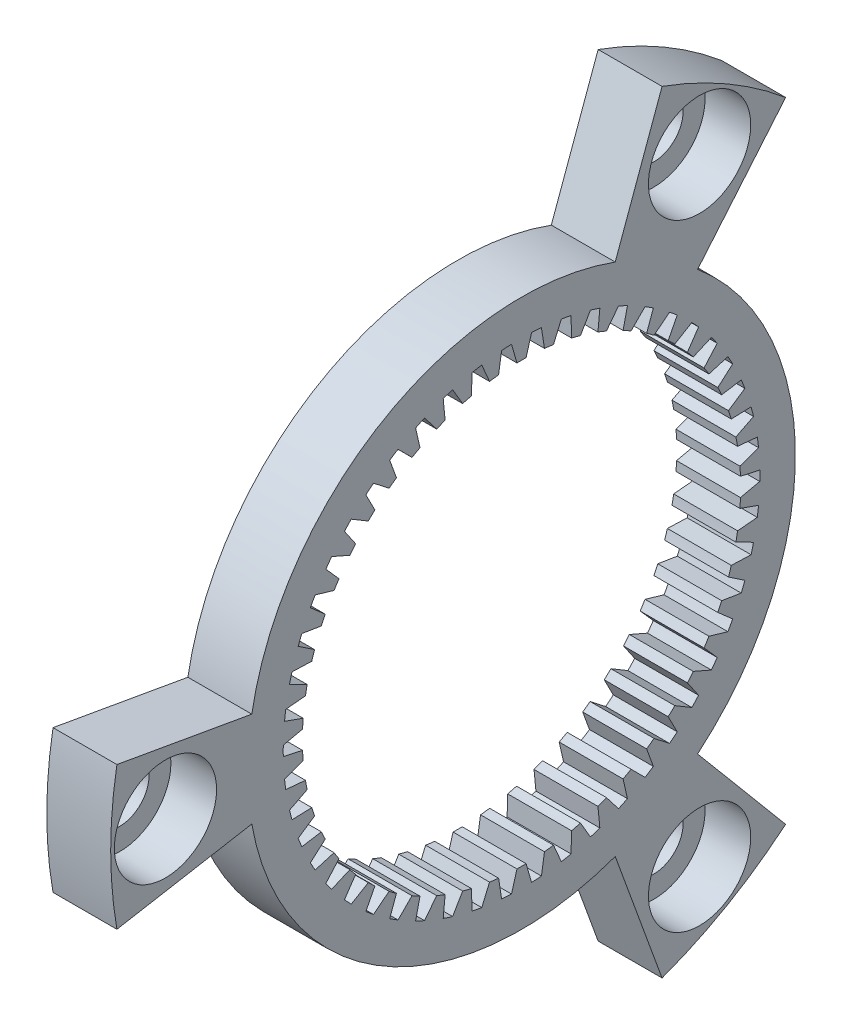
from build123d import *

# Parameters (mm, degrees)
SKETCH1_W                                        = 3.5
SKETCH1_H                                        = 22.5
CUT_EXTRUDE1_DEPTH                               = 4.5
CUT_EXTRUDE2_DEPTH                               = 4.5
CUT_EXTRUDE3_DEPTH                               = 4.5
CUT_EXTRUDE4_DEPTH                               = 4.5
CBORE_FOR_M3_HEX_HEAD_MACHINE_SCREW1_D           = 3.2
CBORE_FOR_M3_HEX_HEAD_MACHINE_SCREW1_CBORE_D     = 5.6
CBORE_FOR_M3_HEX_HEAD_MACHINE_SCREW1_CBORE_DEPTH = 2.5


with BuildPart() as part:
    # Sketch1 → Revolve1 (revolve)
    with BuildSketch(Plane.XY):
        with Locations((0.25, 11.25)):
            Rectangle(SKETCH1_W, SKETCH1_H)
    revolve(axis=Axis((-1.5, 0, 0), (1, 0, 0)))

    # Sketch2 → Cut-Extrude1 (cut, through all)
    with BuildSketch(Plane.ZY.offset(1.5)):
        with BuildLine():
            Line((22.158174437, -3.907084003), (14.77211629, -2.604722668))
            ThreePointArc((14.77211629, -2.604722668), (7.499999995, -12.990381056), (-5.130302151, -14.095389311))
            Line((-5.130302151, -14.095389311), (-7.695453225, -21.143083968))
            ThreePointArc((-7.695453225, -21.143083968), (11.249999994, -19.485571584), (22.158174437, -3.907084003))
        make_face()
    extrude(amount=-CUT_EXTRUDE1_DEPTH, mode=Mode.SUBTRACT)

    # Sketch3 → Cut-Extrude2 (cut, through all)
    with BuildSketch(Plane.ZY.offset(1.5)):
        with BuildLine():
            Line((-14.462721218, -17.23599997), (-9.641814144, -11.490666648))
            ThreePointArc((-9.641814144, -11.490666648), (-14.999999996, -2e-09), (-9.641814142, 11.490666643))
            Line((-9.641814142, 11.490666643), (-14.462721215, 17.235999966))
            ThreePointArc((-14.462721215, 17.235999966), (-22.499999996, -1e-09), (-14.462721218, -17.23599997))
        make_face()
    extrude(amount=-CUT_EXTRUDE2_DEPTH, mode=Mode.SUBTRACT)

    # Sketch4 → Cut-Extrude3 (cut, through all)
    with BuildSketch(Plane.ZY.offset(1.5)):
        with BuildLine():
            Line((-7.695453229, 21.143083966), (-5.130302153, 14.095389311))
            ThreePointArc((-5.130302153, 14.095389311), (7.500000001, 12.990381056), (14.772116296, 2.60472266))
            Line((14.772116296, 2.60472266), (22.158174444, 3.90708399))
            ThreePointArc((22.158174444, 3.90708399), (11.250000001, 19.485571584), (-7.695453229, 21.143083966))
        make_face()
    extrude(amount=-CUT_EXTRUDE3_DEPTH, mode=Mode.SUBTRACT)

    # Sketch5 → Cut-Extrude4 (cut, through all)
    with BuildSketch(Plane.ZY.offset(1.5)):
        with BuildLine():
            Line((11.958023801, 1.002829383), (12.978235019, 1.366717155))
            ThreePointArc((12.978235019, 1.366717155), (12.947096852, 1.635598699), (12.910388636, 1.903776582))
            Line((12.910388636, 1.903776582), (11.83173402, 2.002515937))
            ThreePointArc((11.83173402, 2.002515937), (11.787447009, 2.248575775), (11.738043363, 2.493659563))
            Line((11.738043363, 2.493659563), (12.704602679, 2.982544343))
            ThreePointArc((12.704602679, 2.982544343), (12.640010253, 3.245403028), (12.569979891, 3.506865488))
            Line((12.569979891, 3.506865488), (11.487455466, 3.469634984))
            ThreePointArc((11.487455466, 3.469634984), (11.412678196, 3.708203932), (11.332946969, 3.945163242))
            Line((11.332946969, 3.945163242), (12.230611166, 4.551335025))
            ThreePointArc((12.230611166, 4.551335025), (12.133583141, 4.804025412), (12.031335054, 5.05464903))
            Line((12.031335054, 5.05464903), (10.962012876, 4.882035815))
            ThreePointArc((10.962012876, 4.882035815), (10.85792463, 5.109351498), (10.749123231, 5.33444934))
            Line((10.749123231, 5.33444934), (11.563735608, 6.048348435))
            ThreePointArc((11.563735608, 6.048348435), (11.435802174, 6.286885447), (11.302948875, 6.522717741))
            Line((11.302948875, 6.522717741), (10.263692795, 6.217444025))
            ThreePointArc((10.263692795, 6.217444025), (10.131935106, 6.429921539), (9.995779399, 6.639607986))
            Line((9.995779399, 6.639607986), (10.714493032, 7.449975777))
            ThreePointArc((10.714493032, 7.449975777), (10.557671777, 7.670597542), (10.396308442, 7.887919293))
            Line((10.396308442, 7.887919293), (9.403508148, 7.454799428))
            ThreePointArc((9.403508148, 7.454799428), (9.246158914, 7.649087876), (9.084796155, 7.840056047))
            Line((9.084796155, 7.840056047), (9.6962765, 8.73411255))
            ThreePointArc((9.6962765, 8.73411255), (9.513040588, 8.933339732), (9.325712014, 9.128723647))
            Line((9.325712014, 9.128723647), (8.39502456, 8.574588191))
            ThreePointArc((8.39502456, 8.574588191), (8.21456527, 8.74762353), (8.030540244, 8.916861745))
            Line((8.030540244, 8.916861745), (8.525143895, 9.880507151))
            ThreePointArc((8.525143895, 9.880507151), (8.318383067, 10.055197817), (8.108043537, 10.225562576))
            Line((8.108043537, 10.225562576), (7.254146419, 9.559150576))
            ThreePointArc((7.254146419, 9.559150576), (7.053423027, 9.708203933), (6.849637921, 9.853043203))
            Line((6.849637921, 9.853043203), (7.219564679, 10.871080252))
            ThreePointArc((7.219564679, 10.871080252), (6.992539674, 11.018479428), (6.762506366, 11.161138278))
            Line((6.762506366, 11.161138278), (5.998866056, 10.392959446))
            ThreePointArc((5.998866056, 10.392959446), (5.781044088, 10.515680161), (5.560712715, 10.633836283))
            Line((5.560712715, 10.633836283), (5.800128615, 11.690209923))
            ThreePointArc((5.800128615, 11.690209923), (5.556419755, 11.807993035), (5.310320434, 11.920696158))
            Line((5.310320434, 11.920696158), (4.648979992, 11.062865137))
            ThreePointArc((4.648979992, 11.062865137), (4.417494632, 11.157317831), (4.184091749, 11.246927413))
            Line((4.184091749, 11.246927413), (4.289221057, 12.324978001))
            ThreePointArc((4.289221057, 12.324978001), (4.032671777, 12.411287537), (3.774387577, 12.492257539))
            Line((3.774387577, 12.492257539), (3.225776736, 11.558302836))
            ThreePointArc((3.225776736, 11.558302836), (2.984278646, 11.622997933), (2.741485156, 11.682647779))
            Line((2.741485156, 11.682647779), (2.710669922, 12.765373812))
            ThreePointArc((2.710669922, 12.765373812), (2.445326155, 12.818848622), (2.17893037, 12.866808557))
            Line((2.17893037, 12.866808557), (1.751701054, 11.871459195))
            ThreePointArc((1.751701054, 11.871459195), (1.503998804, 11.905376416), (1.255643705, 11.934125811))
            Line((1.255643705, 11.934125811), (1.089369902, 13.004452054))
            ThreePointArc((1.089369902, 13.004452054), (0.81941628, 13.024248806), (0.549110132, 13.038442317))
            Line((0.549110132, 13.038442317), (0.25, 11.997395551))
            ThreePointArc((0.25, 11.997395551), (1e-09, 12), (-0.249999997, 11.997395551))
            Line((-0.249999997, 11.997395551), (-0.549110132, 13.038442317))
            ThreePointArc((-0.549110132, 13.038442317), (-0.819416279, 13.024248806), (-1.0893699, 13.004452054))
            Line((-1.0893699, 13.004452054), (-1.255643703, 11.934125812))
            ThreePointArc((-1.255643703, 11.934125812), (-1.503998803, 11.905376416), (-1.751701056, 11.871459195))
            Line((-1.751701056, 11.871459195), (-2.17893037, 12.866808557))
            ThreePointArc((-2.17893037, 12.866808557), (-2.445326153, 12.818848622), (-2.710669918, 12.765373813))
            Line((-2.710669918, 12.765373813), (-2.741485155, 11.68264778))
            ThreePointArc((-2.741485155, 11.68264778), (-2.984278646, 11.622997933), (-3.225776737, 11.558302836))
            Line((-3.225776737, 11.558302836), (-3.774387576, 12.492257539))
            ThreePointArc((-3.774387576, 12.492257539), (-4.032671778, 12.411287537), (-4.289221059, 12.324978))
            Line((-4.289221059, 12.324978), (-4.184091749, 11.246927413))
            ThreePointArc((-4.184091749, 11.246927413), (-4.417494632, 11.157317831), (-4.648979992, 11.062865137))
            Line((-4.648979992, 11.062865137), (-5.310320434, 11.920696158))
            ThreePointArc((-5.310320434, 11.920696158), (-5.556419755, 11.807993035), (-5.800128615, 11.690209923))
            Line((-5.800128615, 11.690209923), (-5.560712716, 10.633836283))
            ThreePointArc((-5.560712716, 10.633836283), (-5.781044089, 10.515680161), (-5.998866056, 10.392959446))
            Line((-5.998866056, 10.392959446), (-6.762506367, 11.161138277))
            ThreePointArc((-6.762506367, 11.161138277), (-6.992539674, 11.018479428), (-7.219564678, 10.871080253))
            Line((-7.219564678, 10.871080253), (-6.849637922, 9.853043202))
            ThreePointArc((-6.849637922, 9.853043202), (-7.053423027, 9.708203933), (-7.254146418, 9.559150576))
            Line((-7.254146418, 9.559150576), (-8.108043535, 10.225562578))
            ThreePointArc((-8.108043535, 10.225562578), (-8.318383066, 10.055197818), (-8.525143896, 9.880507151))
            Line((-8.525143896, 9.880507151), (-8.030540246, 8.916861744))
            ThreePointArc((-8.030540246, 8.916861744), (-8.21456527, 8.74762353), (-8.395024558, 8.574588192))
            Line((-8.395024558, 8.574588192), (-9.325712013, 9.128723648))
            ThreePointArc((-9.325712013, 9.128723648), (-9.513040588, 8.933339732), (-9.696276499, 8.73411255))
            Line((-9.696276499, 8.73411255), (-9.084796153, 7.840056049))
            ThreePointArc((-9.084796153, 7.840056049), (-9.246158912, 7.649087878), (-9.403508146, 7.45479943))
            Line((-9.403508146, 7.45479943), (-10.396308442, 7.887919294))
            ThreePointArc((-10.396308442, 7.887919294), (-10.557671776, 7.670597543), (-10.714493031, 7.449975778))
            Line((-10.714493031, 7.449975778), (-9.995779398, 6.639607987))
            ThreePointArc((-9.995779398, 6.639607987), (-10.131935107, 6.429921539), (-10.263692796, 6.217444023))
            Line((-10.263692796, 6.217444023), (-11.302948876, 6.52271774))
            ThreePointArc((-11.302948876, 6.52271774), (-11.435802174, 6.286885448), (-11.563735606, 6.048348438))
            Line((-11.563735606, 6.048348438), (-10.749123231, 5.334449341))
            ThreePointArc((-10.749123231, 5.334449341), (-10.85792463, 5.109351498), (-10.962012877, 4.882035814))
            Line((-10.962012877, 4.882035814), (-12.031335054, 5.054649031))
            ThreePointArc((-12.031335054, 5.054649031), (-12.133583141, 4.804025412), (-12.230611166, 4.551335023))
            Line((-12.230611166, 4.551335023), (-11.332946969, 3.945163242))
            ThreePointArc((-11.332946969, 3.945163242), (-11.412678196, 3.708203932), (-11.487455466, 3.469634984))
            Line((-11.487455466, 3.469634984), (-12.569979891, 3.506865487))
            ThreePointArc((-12.569979891, 3.506865487), (-12.640010253, 3.245403027), (-12.704602679, 2.982544343))
            Line((-12.704602679, 2.982544343), (-11.738043363, 2.493659563))
            ThreePointArc((-11.738043363, 2.493659563), (-11.787447009, 2.248575775), (-11.83173402, 2.002515937))
            Line((-11.83173402, 2.002515937), (-12.910388636, 1.90377658))
            ThreePointArc((-12.910388636, 1.90377658), (-12.947096852, 1.635598698), (-12.978235019, 1.366717156))
            Line((-12.978235019, 1.366717156), (-11.958023801, 1.002829382))
            ThreePointArc((-11.958023801, 1.002829382), (-11.976320741, 0.753486235), (-11.989419061, 0.503816019))
            Line((-11.989419061, 0.503816019), (-13.04719284, 0.270663979))
            ThreePointArc((-13.04719284, 0.270663979), (-13.05, -1e-09), (-13.04719284, -0.270663981))
            Line((-13.04719284, -0.270663981), (-11.989419061, -0.503816018))
            ThreePointArc((-11.989419061, -0.503816018), (-11.976320741, -0.753486235), (-11.958023801, -1.002829382))
            Line((-11.958023801, -1.002829382), (-12.978235019, -1.366717157))
            ThreePointArc((-12.978235019, -1.366717157), (-12.947096852, -1.635598699), (-12.910388636, -1.90377658))
            Line((-12.910388636, -1.90377658), (-11.83173402, -2.002515936))
            ThreePointArc((-11.83173402, -2.002515936), (-11.787447009, -2.248575775), (-11.738043363, -2.493659563))
            Line((-11.738043363, -2.493659563), (-12.704602679, -2.982544343))
            ThreePointArc((-12.704602679, -2.982544343), (-12.640010253, -3.245403027), (-12.569979891, -3.506865487))
            Line((-12.569979891, -3.506865487), (-11.487455466, -3.469634983))
            ThreePointArc((-11.487455466, -3.469634983), (-11.412678196, -3.708203931), (-11.332946969, -3.945163242))
            Line((-11.332946969, -3.945163242), (-12.230611166, -4.551335024))
            ThreePointArc((-12.230611166, -4.551335024), (-12.133583141, -4.804025412), (-12.031335054, -5.054649031))
            Line((-12.031335054, -5.054649031), (-10.962012877, -4.882035813))
            ThreePointArc((-10.962012877, -4.882035813), (-10.85792463, -5.109351497), (-10.749123231, -5.334449341))
            Line((-10.749123231, -5.334449341), (-11.563735609, -6.048348433))
            ThreePointArc((-11.563735609, -6.048348433), (-11.435802175, -6.286885446), (-11.302948876, -6.52271774))
            Line((-11.302948876, -6.52271774), (-10.263692794, -6.217444027))
            ThreePointArc((-10.263692794, -6.217444027), (-10.131935105, -6.429921541), (-9.995779398, -6.639607987))
            Line((-9.995779398, -6.639607987), (-10.714493034, -7.449975773))
            ThreePointArc((-10.714493034, -7.449975773), (-10.557671778, -7.670597541), (-10.396308442, -7.887919294))
            Line((-10.396308442, -7.887919294), (-9.403508147, -7.454799429))
            ThreePointArc((-9.403508147, -7.454799429), (-9.246158913, -7.649087878), (-9.084796153, -7.840056049))
            Line((-9.084796153, -7.840056049), (-9.696276504, -8.734112546))
            ThreePointArc((-9.696276504, -8.734112546), (-9.51304059, -8.93333973), (-9.325712013, -9.128723648))
            Line((-9.325712013, -9.128723648), (-8.395024559, -8.574588191))
            ThreePointArc((-8.395024559, -8.574588191), (-8.214565271, -8.747623529), (-8.030540246, -8.916861744))
            Line((-8.030540246, -8.916861744), (-8.525143893, -9.880507153))
            ThreePointArc((-8.525143893, -9.880507153), (-8.318383065, -10.055197819), (-8.108043535, -10.225562578))
            Line((-8.108043535, -10.225562578), (-7.254146419, -9.559150576))
            ThreePointArc((-7.254146419, -9.559150576), (-7.053423027, -9.708203933), (-6.849637922, -9.853043202))
            Line((-6.849637922, -9.853043202), (-7.219564677, -10.871080253))
            ThreePointArc((-7.219564677, -10.871080253), (-6.992539674, -11.018479428), (-6.762506367, -11.161138277))
            Line((-6.762506367, -11.161138277), (-5.998866057, -10.392959445))
            ThreePointArc((-5.998866057, -10.392959445), (-5.78104409, -10.51568016), (-5.560712716, -10.633836283))
            Line((-5.560712716, -10.633836283), (-5.800128615, -11.690209923))
            ThreePointArc((-5.800128615, -11.690209923), (-5.556419755, -11.807993035), (-5.310320434, -11.920696158))
            Line((-5.310320434, -11.920696158), (-4.648979993, -11.062865136))
            ThreePointArc((-4.648979993, -11.062865136), (-4.417494633, -11.15731783), (-4.184091749, -11.246927413))
            Line((-4.184091749, -11.246927413), (-4.289221058, -12.324978))
            ThreePointArc((-4.289221058, -12.324978), (-4.032671777, -12.411287537), (-3.774387576, -12.492257539))
            Line((-3.774387576, -12.492257539), (-3.225776739, -11.558302835))
            ThreePointArc((-3.225776739, -11.558302835), (-2.984278647, -11.622997933), (-2.741485155, -11.68264778))
            Line((-2.741485155, -11.68264778), (-2.710669925, -12.765373812))
            ThreePointArc((-2.710669925, -12.765373812), (-2.445326157, -12.818848622), (-2.17893037, -12.866808557))
            Line((-2.17893037, -12.866808557), (-1.751701051, -11.871459195))
            ThreePointArc((-1.751701051, -11.871459195), (-1.503998801, -11.905376416), (-1.255643703, -11.934125812))
            Line((-1.255643703, -11.934125812), (-1.089369906, -13.004452053))
            ThreePointArc((-1.089369906, -13.004452053), (-0.819416282, -13.024248806), (-0.549110132, -13.038442317))
            Line((-0.549110132, -13.038442317), (-0.249999998, -11.997395551))
            ThreePointArc((-0.249999998, -11.997395551), (1e-09, -12), (0.25, -11.997395551))
            Line((0.25, -11.997395551), (0.549110126, -13.038442317))
            ThreePointArc((0.549110126, -13.038442317), (0.819416277, -13.024248806), (1.089369902, -13.004452054))
            Line((1.089369902, -13.004452054), (1.255643704, -11.934125812))
            ThreePointArc((1.255643704, -11.934125812), (1.503998803, -11.905376416), (1.751701054, -11.871459195))
            Line((1.751701054, -11.871459195), (2.178930373, -12.866808556))
            ThreePointArc((2.178930373, -12.866808556), (2.445326157, -12.818848622), (2.710669922, -12.765373812))
            Line((2.710669922, -12.765373812), (2.741485155, -11.68264778))
            ThreePointArc((2.741485155, -11.68264778), (2.984278646, -11.622997934), (3.225776736, -11.558302836))
            Line((3.225776736, -11.558302836), (3.774387577, -12.492257539))
            ThreePointArc((3.774387577, -12.492257539), (4.032671777, -12.411287537), (4.289221057, -12.324978001))
            Line((4.289221057, -12.324978001), (4.184091748, -11.246927413))
            ThreePointArc((4.184091748, -11.246927413), (4.417494632, -11.157317831), (4.648979992, -11.062865137))
            Line((4.648979992, -11.062865137), (5.310320434, -11.920696158))
            ThreePointArc((5.310320434, -11.920696158), (5.556419755, -11.807993034), (5.800128615, -11.690209923))
            Line((5.800128615, -11.690209923), (5.560712715, -10.633836283))
            ThreePointArc((5.560712715, -10.633836283), (5.781044088, -10.515680161), (5.998866056, -10.392959446))
            Line((5.998866056, -10.392959446), (6.762506366, -11.161138277))
            ThreePointArc((6.762506366, -11.161138277), (6.992539674, -11.018479428), (7.219564679, -10.871080252))
            Line((7.219564679, -10.871080252), (6.84963792, -9.853043203))
            ThreePointArc((6.84963792, -9.853043203), (7.053423026, -9.708203933), (7.254146419, -9.559150576))
            Line((7.254146419, -9.559150576), (8.108043533, -10.225562579))
            ThreePointArc((8.108043533, -10.225562579), (8.318383065, -10.055197819), (8.525143895, -9.880507151))
            Line((8.525143895, -9.880507151), (8.030540248, -8.916861742))
            ThreePointArc((8.030540248, -8.916861742), (8.214565272, -8.747623528), (8.39502456, -8.574588191))
            Line((8.39502456, -8.574588191), (9.32571201, -9.128723651))
            ThreePointArc((9.32571201, -9.128723651), (9.513040587, -8.933339734), (9.6962765, -8.73411255))
            Line((9.6962765, -8.73411255), (9.084796154, -7.840056048))
            ThreePointArc((9.084796154, -7.840056048), (9.246158914, -7.649087876), (9.403508148, -7.454799428))
            Line((9.403508148, -7.454799428), (10.396308438, -7.887919298))
            ThreePointArc((10.396308438, -7.887919298), (10.557671775, -7.670597545), (10.714493032, -7.449975777))
            Line((10.714493032, -7.449975777), (9.995779399, -6.639607986))
            ThreePointArc((9.995779399, -6.639607986), (10.131935106, -6.429921539), (10.263692795, -6.217444025))
            Line((10.263692795, -6.217444025), (11.302948877, -6.522717737))
            ThreePointArc((11.302948877, -6.522717737), (11.435802175, -6.286885446), (11.563735608, -6.048348435))
            Line((11.563735608, -6.048348435), (10.749123231, -5.334449341))
            ThreePointArc((10.749123231, -5.334449341), (10.85792463, -5.109351498), (10.962012876, -4.882035815))
            Line((10.962012876, -4.882035815), (12.031335054, -5.05464903))
            ThreePointArc((12.031335054, -5.05464903), (12.133583141, -4.804025412), (12.230611166, -4.551335025))
            Line((12.230611166, -4.551335025), (11.332946968, -3.945163243))
            ThreePointArc((11.332946968, -3.945163243), (11.412678195, -3.708203933), (11.487455466, -3.469634984))
            Line((11.487455466, -3.469634984), (12.569979891, -3.506865487))
            ThreePointArc((12.569979891, -3.506865487), (12.640010253, -3.245403027), (12.704602679, -2.982544343))
            Line((12.704602679, -2.982544343), (11.738043362, -2.493659564))
            ThreePointArc((11.738043362, -2.493659564), (11.787447009, -2.248575776), (11.83173402, -2.002515937))
            Line((11.83173402, -2.002515937), (12.910388636, -1.903776581))
            ThreePointArc((12.910388636, -1.903776581), (12.947096852, -1.635598699), (12.978235019, -1.366717155))
            Line((12.978235019, -1.366717155), (11.958023801, -1.002829385))
            ThreePointArc((11.958023801, -1.002829385), (11.976320741, -0.753486236), (11.989419061, -0.503816018))
            Line((11.989419061, -0.503816018), (13.04719284, -0.27066398))
            ThreePointArc((13.04719284, -0.27066398), (13.05, -1e-09), (13.04719284, 0.270663979))
            Line((13.04719284, 0.270663979), (11.989419061, 0.503816018))
            ThreePointArc((11.989419061, 0.503816018), (11.976320741, 0.753486235), (11.958023801, 1.002829383))
        make_face()
    extrude(amount=-CUT_EXTRUDE4_DEPTH, mode=Mode.SUBTRACT)

    # CBORE for M3 Hex Head Machine Screw1 (through all)
    with Locations(Plane(origin=(2, 0, 0), x_dir=(0, 0, -1), z_dir=(1, 0, 0))):
        with Locations((9.75, -16.887495374), (-19.5, 0), (9.75, 16.887495374)):
            CounterBoreHole(CBORE_FOR_M3_HEX_HEAD_MACHINE_SCREW1_D / 2, CBORE_FOR_M3_HEX_HEAD_MACHINE_SCREW1_CBORE_D / 2, CBORE_FOR_M3_HEX_HEAD_MACHINE_SCREW1_CBORE_DEPTH)


solid = part.part
